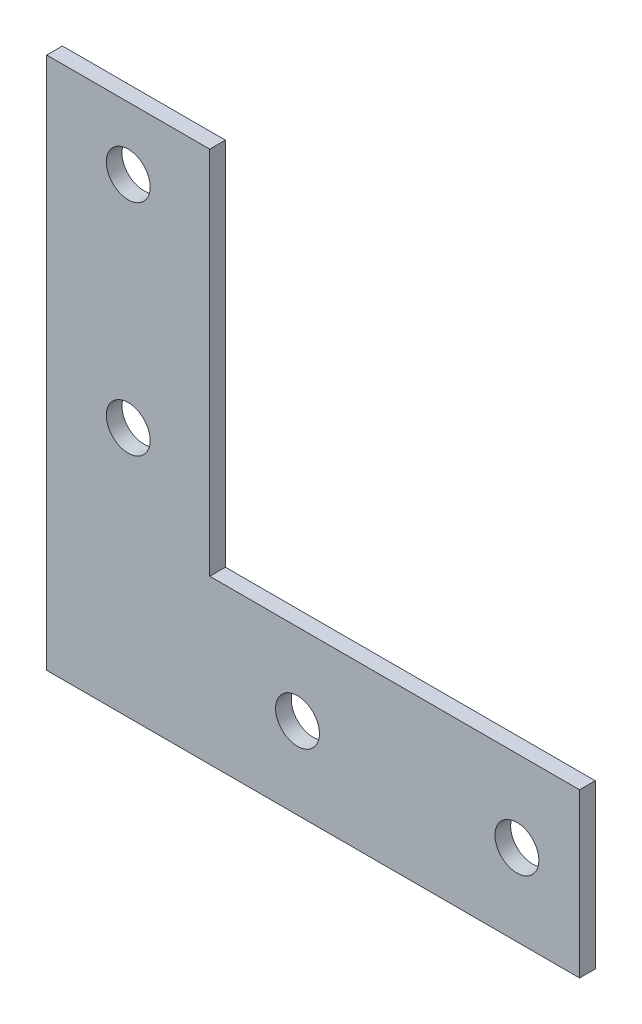
from build123d import *

# Parameters (mm, degrees)
SKETCH_1_R      = 3.5
EXTRUDE_1_DEPTH = 2.5


with BuildPart() as part:
    # Эскиз1 → Бобышка-Вытянуть1 (new body)
    with BuildSketch(Plane.XY):
        Polygon((0, 85), (0, 0), (85, 0), (85, 26), (26, 26), (26, 85), align=None)
        with Locations((13, 75)):
            Circle(SKETCH_1_R, mode=Mode.SUBTRACT)
        with Locations((13, 40)):
            Circle(SKETCH_1_R, mode=Mode.SUBTRACT)
        with Locations((40, 13)):
            Circle(SKETCH_1_R, mode=Mode.SUBTRACT)
        with Locations((75, 13)):
            Circle(SKETCH_1_R, mode=Mode.SUBTRACT)
    extrude(amount=EXTRUDE_1_DEPTH)


solid = part.part
